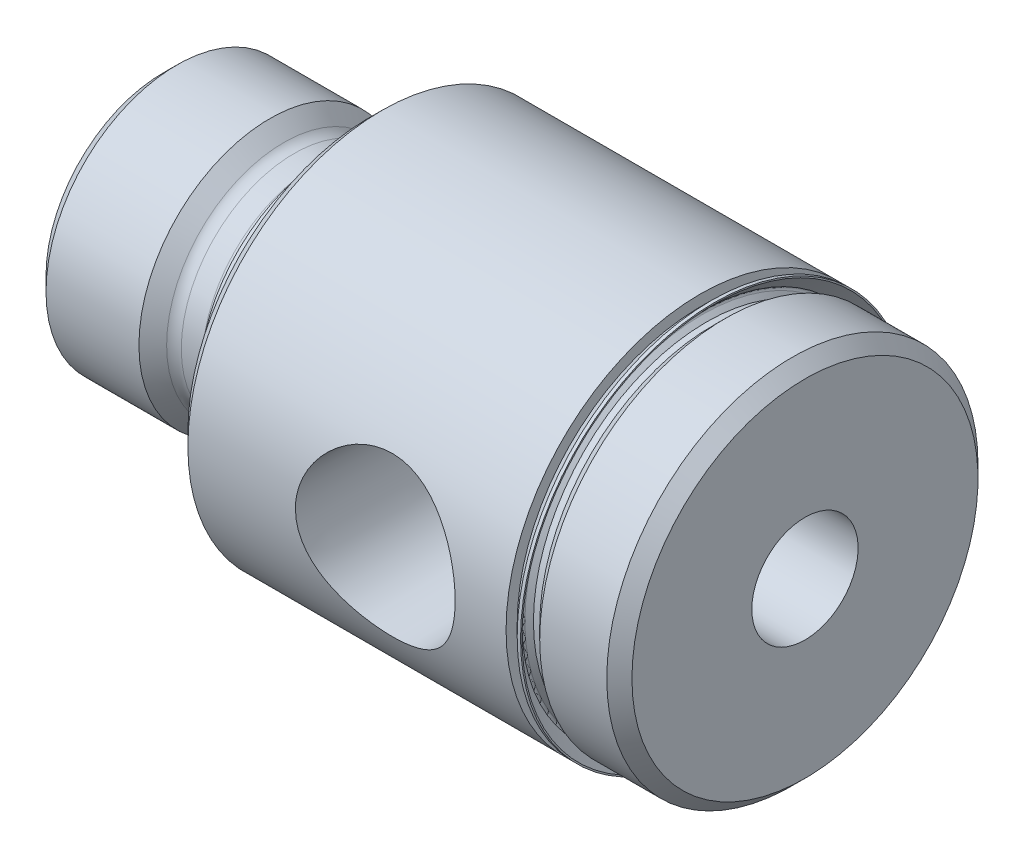
from build123d import *

# Parameters (mm, degrees)
HOLE1_D           = 6.4389
HOLE1_CSINK_D     = 7.9629
HOLE1_CSINK_ANGLE = 90


with BuildPart() as part:
    # Sketch1 → Revolve1 (revolve)
    with BuildSketch(Plane.XY):
        with BuildLine():
            Line((0, 0), (0, 7.09803))
            Line((0, 7.09803), (0.83947, 7.9375))
            Line((0.83947, 7.9375), (6.469412072, 7.9375))
            Line((6.469412072, 7.9375), (7.30937001, 7.098844511))
            ThreePointArc((7.30937001, 7.098844511), (7.597613092, 6.906489173), (7.9375, 6.83895))
            Line((7.9375, 6.83895), (9.2202, 6.83895))
            ThreePointArc((9.2202, 6.83895), (9.848817928, 7.099332072), (10.1092, 7.72795))
            Line((10.1092, 7.72795), (10.1092, 7.90575))
            Line((10.1092, 7.90575), (12.4968, 7.90575))
            Line((12.4968, 7.90575), (12.4968, 0))
            Line((12.4968, 0), (0, 0))
        make_face()
    revolve(axis=Axis((12.4968, 0, 0), (-1, 0, 0)))

    # Sketch2 → Revolve2 (revolve)
    with BuildSketch(Plane.XY):
        Polygon((12.4968, 0), (12.4968, 10.9982), (13.2588, 11.7602), (32.5374, 11.7602), (32.5374, 10.48385), (33.2994, 10.48385), (34.0614, 11.24585), (38.1254, 11.24585), (38.8874, 10.48385), (38.8874, 0), align=None)
    revolve(axis=Axis((38.8874, 0, 0), (-1, 0, 0)))

    # Hole1 (through all)
    with Locations(Plane.ZY):
        with Locations((0, 0)):
            CounterSinkHole(HOLE1_D / 2, HOLE1_CSINK_D / 2, counter_sink_angle=HOLE1_CSINK_ANGLE)

    # Sketch5 → Cut-Revolve1 (revolve, cut)
    with BuildSketch(Plane(origin=(0, 0, 0), x_dir=(1, 0, 0), z_dir=(0, 1, 0))):
        Polygon((24.6126, 0), (27.7876, 0), (27.7876, -2.713616984), (29.214183016, -4.1402), (29.452075925, -11.7602), (24.6126, -11.7602), align=None)
    revolve(axis=Axis((24.6126, 0, 11.7602), (0, 0, -1)), mode=Mode.SUBTRACT)

    # Sketch6 → Revolve3 (revolve)
    with BuildSketch(Plane.XY):
        with BuildLine():
            Line((32.5374, 10.22985), (33.2994, 10.22985))
            Line((33.2994, 10.22985), (33.2994, 10.48385))
            Line((33.2994, 10.48385), (32.9184, 10.48385))
            Line((32.9184, 10.48385), (32.659887194, 10.742362806))
            ThreePointArc((32.659887194, 10.742362806), (32.622689755, 10.832165367), (32.659887194, 10.921967928))
            Line((32.659887194, 10.921967928), (33.41395107, 11.676031804))
            Line((33.41395107, 11.676031804), (33.41395107, 11.7602))
            Line((33.41395107, 11.7602), (33.21075107, 11.7602))
            Line((33.21075107, 11.7602), (32.5374, 11.08684893))
            Line((32.5374, 11.08684893), (32.5374, 10.22985))
        make_face()
    revolve(axis=Axis((33.2994, 0, 0), (-1, 0, 0)))


solid = part.part
